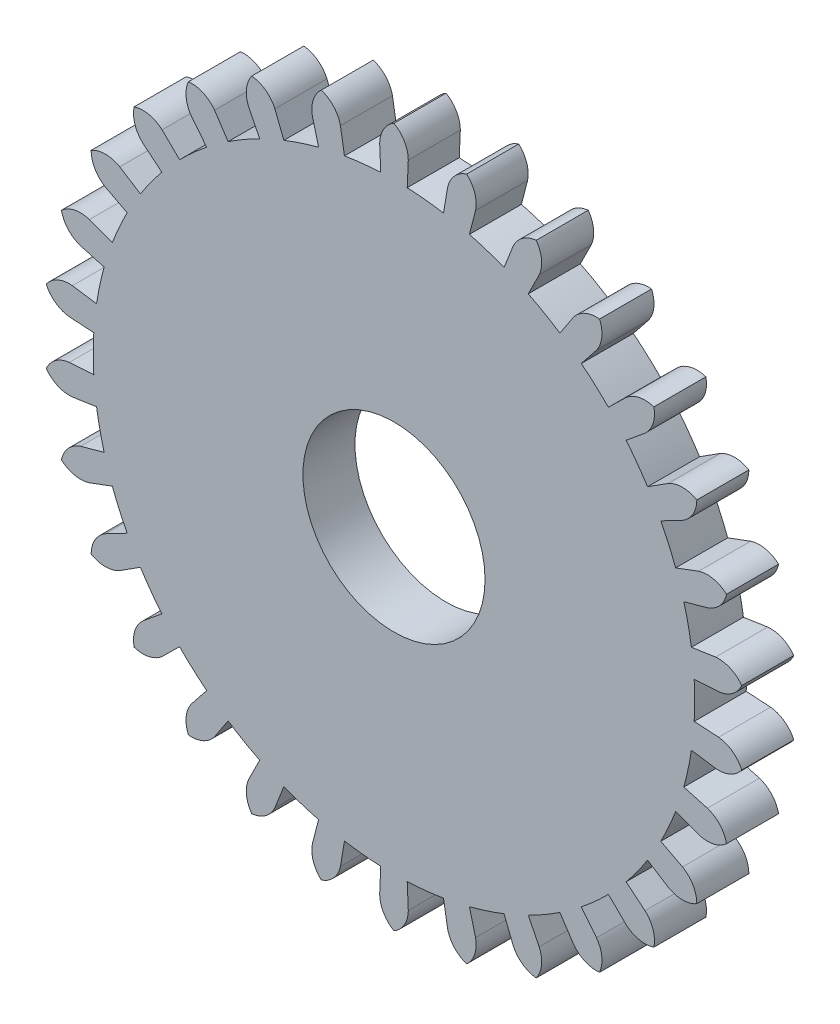
from build123d import *

# Parameters (mm, degrees)
SKETCH1_R           = 3.5
BOSS_EXTRUDE1_DEPTH = 2
CIRPATTERN1_COUNT   = 30


with BuildPart() as part:
    # Sketch1 → Boss-Extrude1 (new body)
    with BuildSketch(Plane.XY):
        with BuildLine():
            Line((-0.55, 12.487894138), (-0.508617028, 11.548282922))
            ThreePointArc((-0.508617028, 11.548282922), (0, -11.559477918), (0.508617028, 11.548282922))
            Line((0.508617028, 11.548282922), (0.55, 12.487894138))
            ThreePointArc((0.55, 12.487894138), (0.402627944, 13.037894138), (0, 13.440522082))
            ThreePointArc((0, 13.440522082), (-0.402627944, 13.037894138), (-0.55, 12.487894138))
        make_face()
        Circle(SKETCH1_R, mode=Mode.SUBTRACT)
    boss_extrude1 = extrude(amount=-BOSS_EXTRUDE1_DEPTH)

    # CirPattern1: Boss-Extrude1 ×30 about axis
    cirpattern1_axis = Axis((0, 0, 0), (0, 0, 1))
    for i in range(1, CIRPATTERN1_COUNT):
        add(boss_extrude1.rotate(cirpattern1_axis, i * 360 / CIRPATTERN1_COUNT))


solid = part.part
